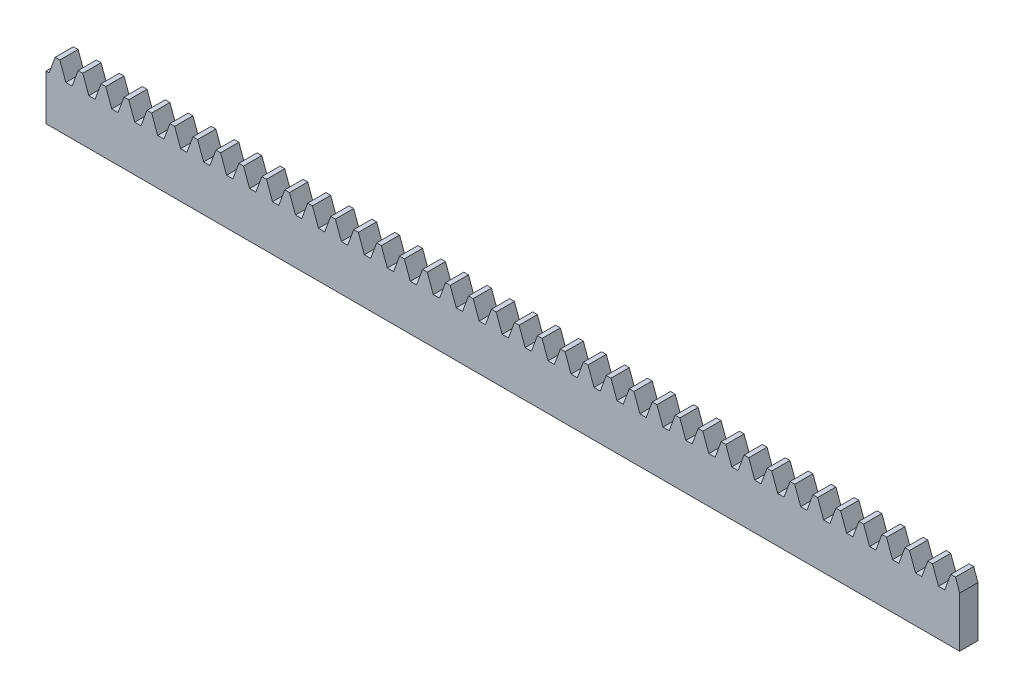
from build123d import *

# Parameters (mm, degrees)
BLANKSKE_W        = 250
BLANKSKE_H        = 17
BLANK_DEPTH       = 5
TOOTHCUTSIM_DEPTH = 251.627213207
TEETHCUTS_COUNT   = 41
TEETHCUTS_PITCH   = 6.2831853


with BuildPart() as part:
    # BlankSke → Blank (new body)
    with BuildSketch(Plane.XY):
        with Locations((125, 8.5)):
            Rectangle(BLANKSKE_W, BLANKSKE_H)
    extrude(amount=-BLANK_DEPTH)

    # TooCutSkeSim → ToothCutSim (cut, through all)
    with BuildSketch(Plane.XY):
        Polygon((0.861870739, 12.5), (-0.861870739, 12.5), (-2.508981637, 17.0254), (2.508981637, 17.0254), align=None)
    toothcutsim = extrude(amount=-TOOTHCUTSIM_DEPTH, mode=Mode.SUBTRACT)

    # TeethCuts: ToothCutSim ×41
    with Locations(*[(i * TEETHCUTS_PITCH, 0, 0) for i in range(1, TEETHCUTS_COUNT)]):
        add(toothcutsim, mode=Mode.SUBTRACT)


solid = part.part
